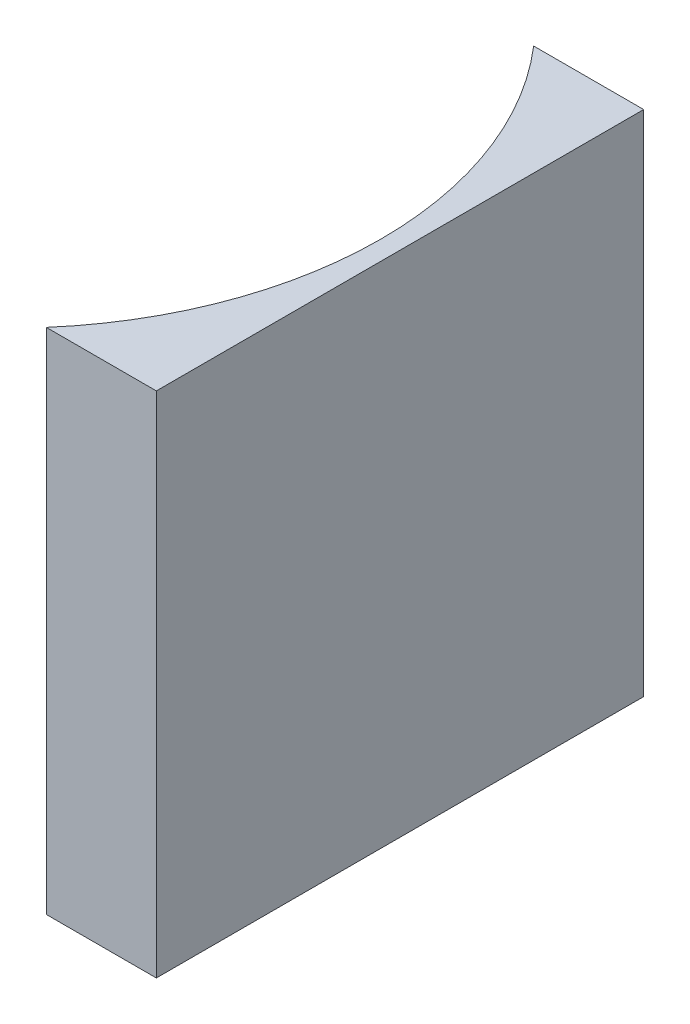
from build123d import *

# Parameters (mm, degrees)
EXTRUDE_1_DEPTH = 53


with BuildPart() as part:
    # 草图1 → 凸台-拉伸1 (new body)
    with BuildSketch(Plane(origin=(0, 0, 0), x_dir=(1, 0, 0), z_dir=(0, 1, 0))):
        with BuildLine():
            Line((0, 0), (0, -50.8))
            Line((0, -50.8), (-11.469469831, -50.8))
            ThreePointArc((-11.469469831, -50.8), (-2, -25.4), (-11.469469831, 0))
            Line((-11.469469831, 0), (0, 0))
        make_face()
    extrude(amount=EXTRUDE_1_DEPTH)


solid = part.part
